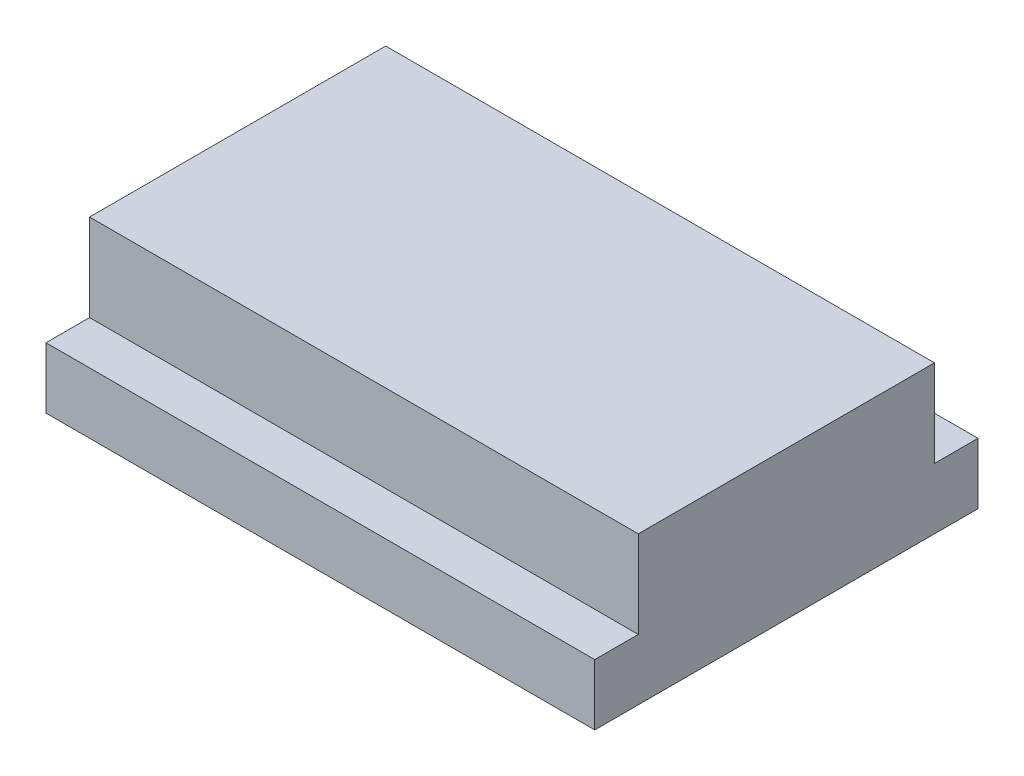
from build123d import *

# Parameters (mm, degrees)
SKETCH1_W           = 63
SKETCH1_H           = 44
BOSS_EXTRUDE1_DEPTH = 17
SKETCH2_W           = 63
SKETCH2_H           = 5
CUT_EXTRUDE1_DEPTH  = 10


with BuildPart() as part:
    # Sketch1 → Boss-Extrude1 (new body)
    with BuildSketch(Plane(origin=(0, 0, 0), x_dir=(1, 0, 0), z_dir=(0, 1, 0))):
        Rectangle(SKETCH1_W, SKETCH1_H)
    extrude(amount=BOSS_EXTRUDE1_DEPTH)

    # Sketch2 → Cut-Extrude1 (cut)
    with BuildSketch(Plane(origin=(0, 17, 0), x_dir=(1, 0, 0), z_dir=(0, 1, 0))):
        with Locations((0, 19.5)):
            Rectangle(SKETCH2_W, SKETCH2_H)
        with Locations((0, -19.5)):
            Rectangle(SKETCH2_W, SKETCH2_H)
    extrude(amount=-CUT_EXTRUDE1_DEPTH, mode=Mode.SUBTRACT)


solid = part.part
